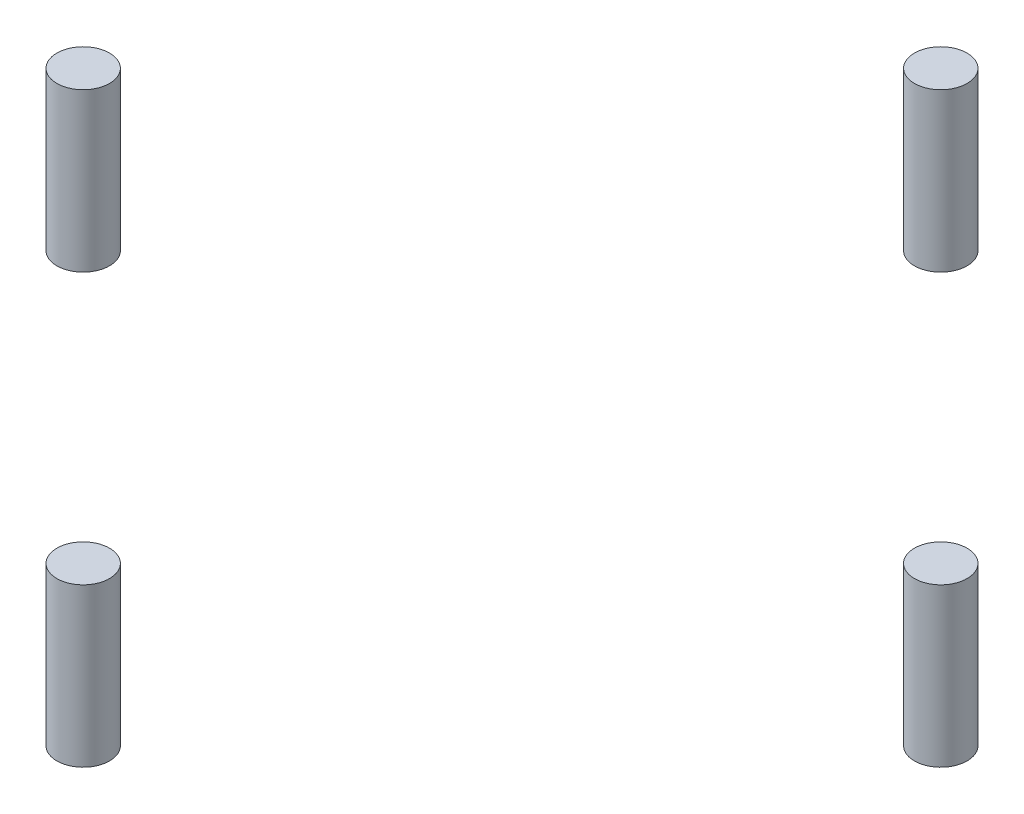
from build123d import *

# Parameters (mm, degrees)
SKETCH_1_R        = 3
EXTRUDE_1_DEPTH   = 18
SKETCH_1_R_2      = 2.999961644
EXTRUDE_1_2_DEPTH = 18
EXTRUDE_1_3_DEPTH = 18
EXTRUDE_1_4_DEPTH = 18


with BuildPart() as part:
    # 草图1 → 凸台-拉伸1 (new body)
    with BuildSketch(Plane(origin=(0, 0, 0), x_dir=(1, 0, 0), z_dir=(0, 1, 0))):
        with Locations((-48.852813742, 0)):
            Circle(SKETCH_1_R)
    extrude(amount=EXTRUDE_1_DEPTH)


with BuildPart() as body_2:
    # 草图1 → Extrude 1 2 (new body)
    with BuildSketch(Plane(origin=(0, 0, 0), x_dir=(1, 0, 0), z_dir=(0, 1, 0))):
        with Locations((0, 48.852813742)):
            Circle(SKETCH_1_R_2)
    extrude(amount=EXTRUDE_1_2_DEPTH)


with BuildPart() as body_3:
    # 草图1 → Extrude 1 3 (new body)
    with BuildSketch(Plane(origin=(0, 0, 0), x_dir=(1, 0, 0), z_dir=(0, 1, 0))):
        with Locations((0, -48.852813742)):
            Circle(SKETCH_1_R_2)
    extrude(amount=EXTRUDE_1_3_DEPTH)


with BuildPart() as body_4:
    # 草图1 → Extrude 1 4 (new body)
    with BuildSketch(Plane(origin=(0, 0, 0), x_dir=(1, 0, 0), z_dir=(0, 1, 0))):
        with Locations((48.852813742, 0)):
            Circle(SKETCH_1_R)
    extrude(amount=EXTRUDE_1_4_DEPTH)


solid = Compound([part.part, body_2.part, body_3.part, body_4.part])
